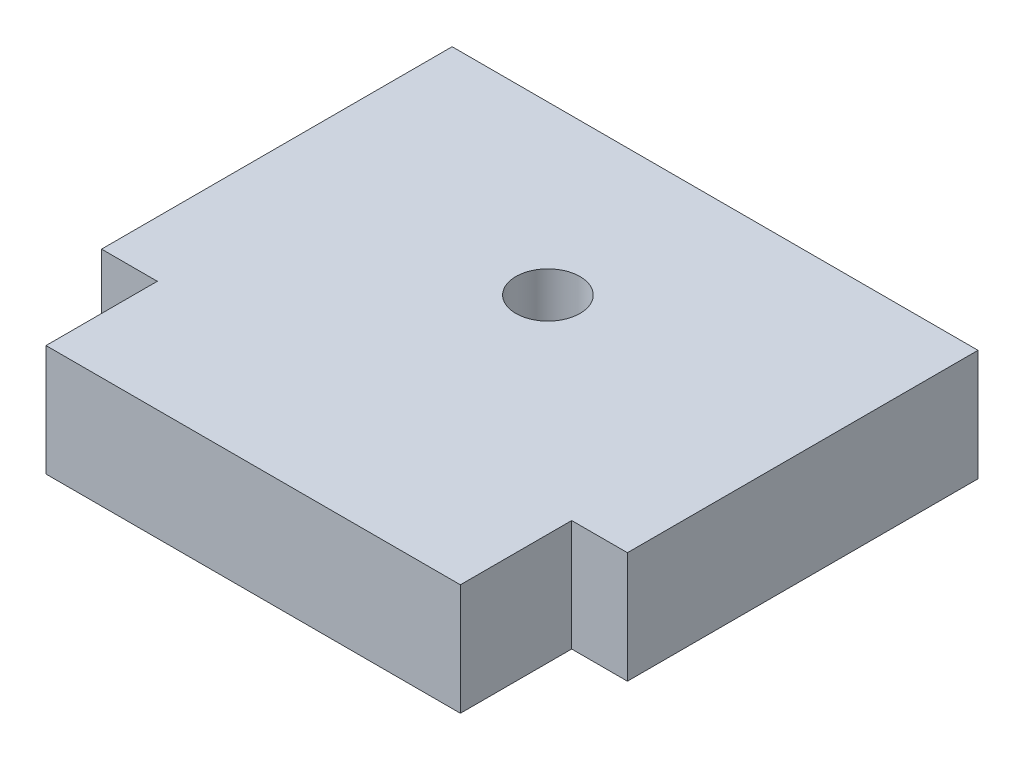
from build123d import *

# Parameters (mm, degrees)
BOSS_EXTRUDE1_DEPTH   = 6.35
F_6_CLEARANCE_HOLE1_D = 3.6576


with BuildPart() as part:
    # Sketch1 → Boss-Extrude1 (new body)
    with BuildSketch(Plane(origin=(0, 0, 0), x_dir=(1, 0, 0), z_dir=(0, 1, 0))):
        Polygon((-15, -10), (-15, 10), (15, 10), (15, -10), (11.82, -10), (11.82, -16.35), (-11.82, -16.35), (-11.82, -10), align=None)
    extrude(amount=BOSS_EXTRUDE1_DEPTH)

    # #6 Clearance Hole1 (through all)
    with Locations(Plane(origin=(0, 6.35, 0), x_dir=(1, 0, 0), z_dir=(0, 1, 0))):
        with Locations((0, 0.4648)):
            Hole(F_6_CLEARANCE_HOLE1_D / 2)


solid = part.part
